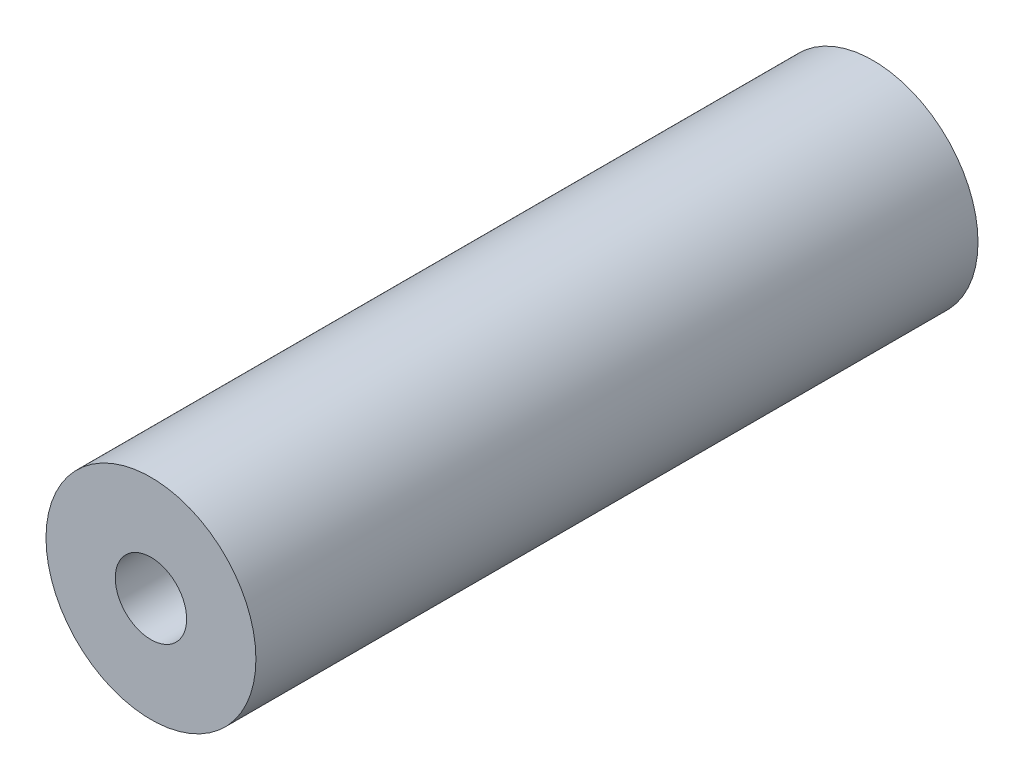
from build123d import *

# Parameters (mm, degrees)
SKETCH_2_W             = 43
SKETCH_2_H             = 12.5
HOLE_WIZARD_M101_D     = 8.5
HOLE_WIZARD_M101_DEPTH = 27.5
HOLE_WIZARD_M101_TIP   = 2.553657631


with BuildPart() as part:
    # Эскиз2 → Повернуть1 (revolve)
    with BuildSketch(Plane(origin=(0, 0, 0), x_dir=(0, 0, -1), z_dir=(1, 0, 0))):
        with Locations((21.5, 6.25)):
            Rectangle(SKETCH_2_W, SKETCH_2_H)
    revolve(axis=Axis((0, 0, 0), (0, 0, -1)))

    # Отверстие обработанное метчиком M101
    with Locations(Plane(origin=(0, 0, -43), x_dir=(-1, 0, 0), z_dir=(0, 0, -1))):
        with Locations((0, 0)):
            Hole(HOLE_WIZARD_M101_D / 2, depth=HOLE_WIZARD_M101_DEPTH)
            with Locations((0, 0, -(HOLE_WIZARD_M101_DEPTH + HOLE_WIZARD_M101_TIP / 2))):  # 118° drill point
                Cone(0, HOLE_WIZARD_M101_D / 2, HOLE_WIZARD_M101_TIP, mode=Mode.SUBTRACT)

    # Зеркальное отражение1: part across plane


with BuildPart() as part_1:
    add(part.part)
    add(part.part.mirror(Plane(origin=(0, 0, 0), x_dir=(1, 0, 0), z_dir=(0, 0, -1))))


solid = part_1.part
